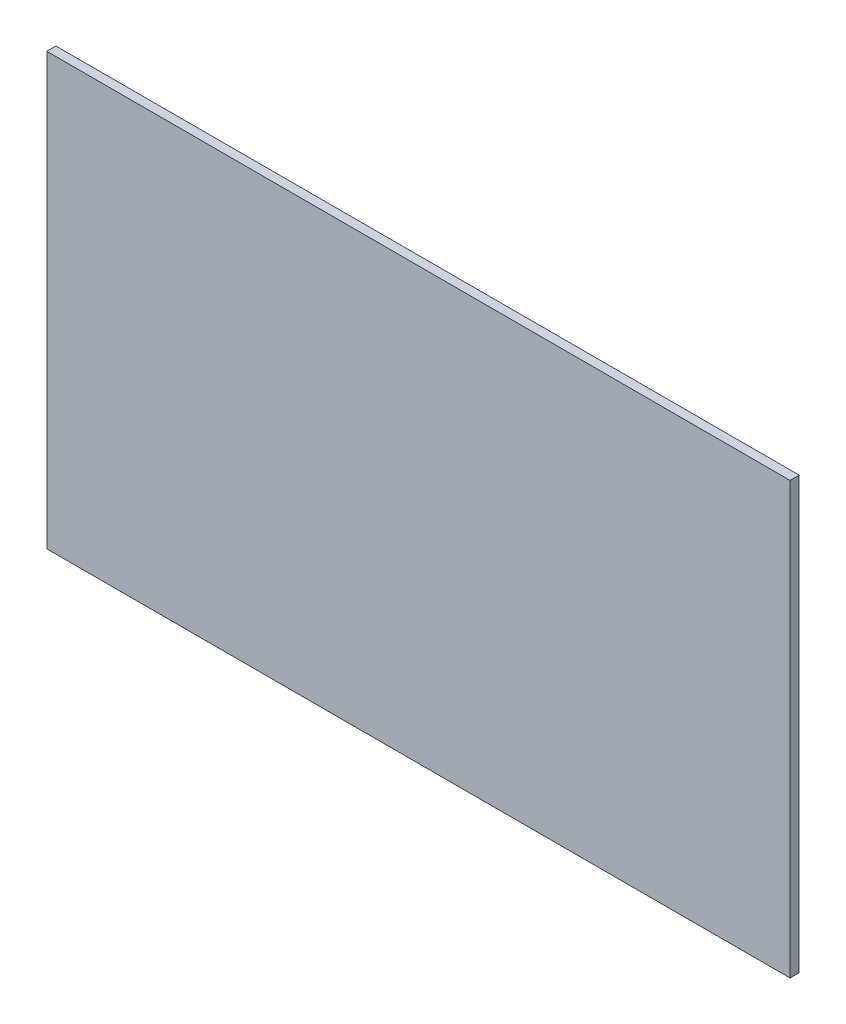
from build123d import *

# Parameters (mm, degrees)
SKETCH1_W           = 163
SKETCH1_H           = 94.5
BOSS_EXTRUDE1_DEPTH = 2


with BuildPart() as part:
    # Sketch1 → Boss-Extrude1 (new body)
    with BuildSketch(Plane.XY):
        with Locations((-77.5, 25.25)):
            Rectangle(SKETCH1_W, SKETCH1_H)
    extrude(amount=BOSS_EXTRUDE1_DEPTH)


solid = part.part
